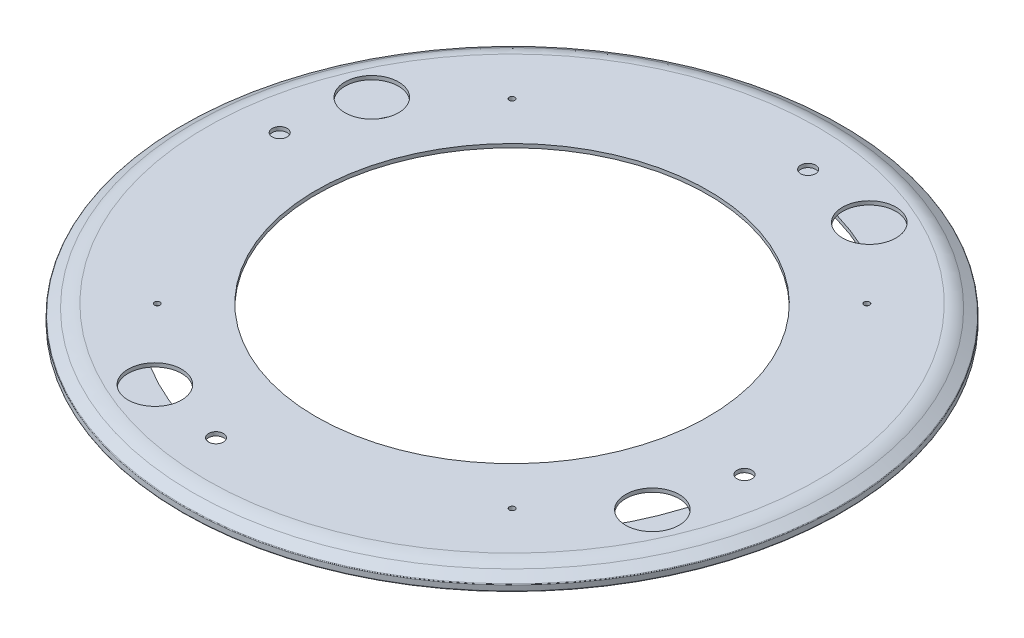
from build123d import *

# Parameters (mm, degrees)
SKETCH_3_R          = 14.325286012
CUT_EXTRUDE_2_DEPTH = 3
SKETCH_4_R          = 4
CUT_EXTRUDE_3_DEPTH = 3
SKETCH_5_R          = 2.5
CUT_EXTRUDE_4_DEPTH = 2
SKETCH_6_R          = 1.5
CUT_EXTRUDE_5_DEPTH = 3


with BuildPart() as part:
    # 草图1 → 旋转1 (revolve)
    with BuildSketch(Plane.XY):
        with BuildLine():
            Line((163.684919254, 9), (105, 9))
            Line((105, 9), (105, 7))
            Line((105, 7), (163.684919254, 7))
            ThreePointArc((163.684919254, 7), (165.90837568, 6.859208887), (168.096314472, 6.439084553))
            Line((168.096314472, 6.439084553), (174.5, 2.656413608))
            Line((174.5, 2.656413608), (174.5, 2))
            Line((174.5, 2), (140.5, 2))
            Line((140.5, 2), (140.5, 0))
            Line((140.5, 0), (176, 0))
            ThreePointArc((176, 0), (176.353553391, 0.146446609), (176.5, 0.5))
            Line((176.5, 0.5), (176.5, 3.231140782))
            ThreePointArc((176.5, 3.231140782), (176.435661844, 3.476495133), (176.259204971, 3.658706898))
            Line((176.259204971, 3.658706898), (171.019179277, 6.835386852))
            ThreePointArc((171.019179277, 6.835386852), (167.508429427, 8.447549196), (163.684919254, 9))
        make_face()
    revolve(axis=Axis((0, 0, 0), (0, -1, 0)))

    # 草图3 → 切除-拉伸2 (cut)
    with BuildSketch(Plane(origin=(0, 9, 0), x_dir=(1, 0, 0), z_dir=(0, 1, 0))):
        with Locations((58.081681413, 133.219094668)):
            Circle(SKETCH_3_R)
        with Locations((133.219094668, -58.081681413)):
            Circle(SKETCH_3_R)
        with Locations((-58.081681413, -133.219094668)):
            Circle(SKETCH_3_R)
        with Locations((-133.219094668, 58.081681413)):
            Circle(SKETCH_3_R)
    extrude(amount=-CUT_EXTRUDE_2_DEPTH, mode=Mode.SUBTRACT)

    # 草图4 → 切除-拉伸3 (cut)
    with BuildSketch(Plane(origin=(0, 9, 0), x_dir=(1, 0, 0), z_dir=(0, 1, 0))):
        with Locations((17.053492548, 141.497897625)):
            Circle(SKETCH_4_R)
        with Locations((141.497897625, -17.053492548)):
            Circle(SKETCH_4_R)
        with Locations((-17.053492548, -141.497897625)):
            Circle(SKETCH_4_R)
        with Locations((-141.497897625, 17.053492548)):
            Circle(SKETCH_4_R)
    extrude(amount=-CUT_EXTRUDE_3_DEPTH, mode=Mode.SUBTRACT)

    # 草图5 → 切除-拉伸4 (cut)
    with BuildSketch(Plane.XZ):
        with Locations((-103.5, 103.5)):
            Circle(SKETCH_5_R)
        with Locations((103.5, 103.5)):
            Circle(SKETCH_5_R)
        with Locations((103.5, -103.5)):
            Circle(SKETCH_5_R)
        with Locations((-103.5, -103.5)):
            Circle(SKETCH_5_R)
    extrude(amount=-CUT_EXTRUDE_4_DEPTH, mode=Mode.SUBTRACT)

    # 草图6 → 切除-拉伸5 (cut)
    with BuildSketch(Plane(origin=(0, 9, 0), x_dir=(1, 0, 0), z_dir=(0, 1, 0))):
        with Locations((-95, 95)):
            Circle(SKETCH_6_R)
        with Locations((95, 95)):
            Circle(SKETCH_6_R)
        with Locations((95, -95)):
            Circle(SKETCH_6_R)
        with Locations((-95, -95)):
            Circle(SKETCH_6_R)
    extrude(amount=-CUT_EXTRUDE_5_DEPTH, mode=Mode.SUBTRACT)


solid = part.part
